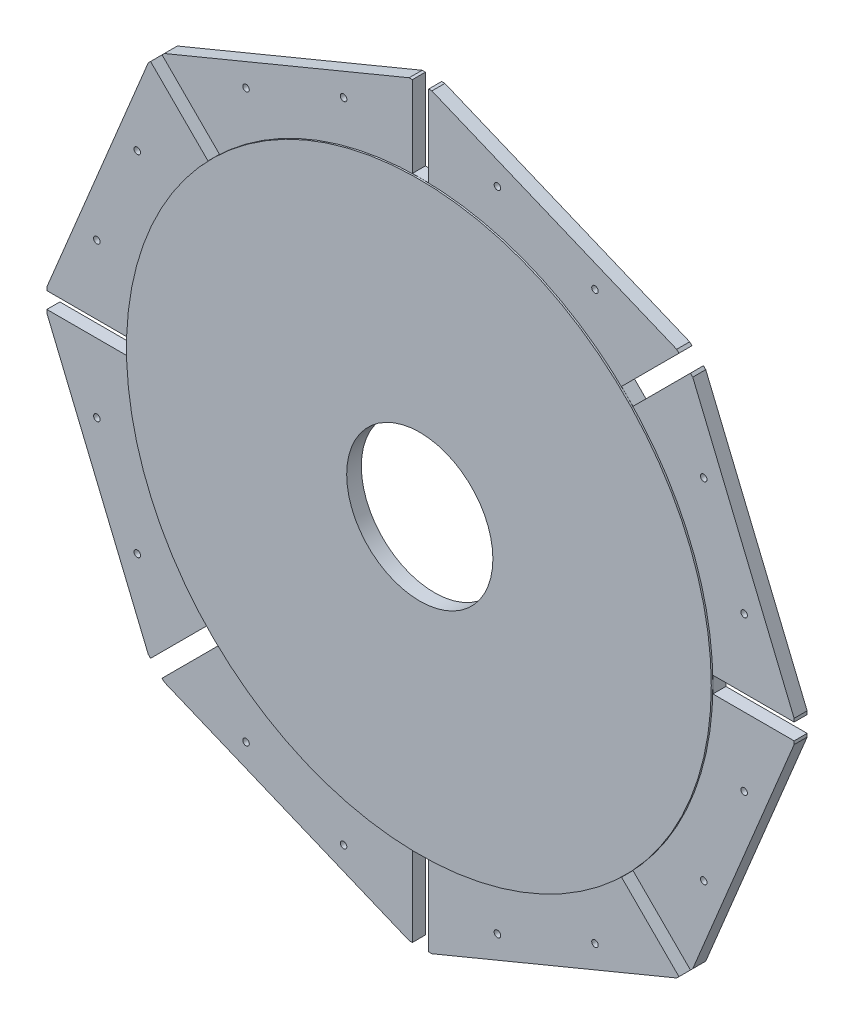
from build123d import *

# Parameters (mm, degrees)
BOSS_EXTRUDE1_DEPTH = 8
SKETCH2_R           = 180
BOSS_EXTRUDE2_DEPTH = 1
CUT_EXTRUDE1_REACH  = 10
SKETCH3_R           = 2
CUT_EXTRUDE2_REACH  = 11
SKETCH4_R           = 45


with BuildPart() as part:
    # Sketch1 → Boss-Extrude1 (new body)
    with BuildSketch(Plane.XY):
        Polygon((5, 230), (5, 180), (-5, 180), (-5, 230), (-7, 230), (-157.684812205, 167.584307141), (-159.099025767, 166.170093579), (-123.743686708, 130.814754519), (-130.81475452, 123.743686708), (-166.170093579, 159.099025767), (-167.584307141, 157.684812205), (-230, 7), (-230, 5), (-180, 5), (-180, -5), (-230, -5), (-230, -7), (-167.584307141, -157.684812205), (-166.170093579, -159.099025767), (-130.81475452, -123.743686708), (-123.743686708, -130.81475452), (-159.099025767, -166.170093579), (-157.684812205, -167.584307141), (-7, -230), (-5, -230), (-5, -180), (5, -180), (5, -230), (7, -230), (157.684812205, -167.584307141), (159.099025767, -166.170093579), (123.743686708, -130.814754519), (130.81475452, -123.743686708), (166.170093579, -159.099025767), (167.584307141, -157.684812205), (230, -7), (230, -5), (180, -5), (180, 5), (230, 5), (230, 7), (167.584307141, 157.684812205), (166.170093579, 159.099025767), (130.81475452, 123.743686708), (123.743686708, 130.81475452), (159.099025767, 166.170093579), (157.684812205, 167.584307141), (7, 230), align=None)
    extrude(amount=BOSS_EXTRUDE1_DEPTH)

    # Sketch2 → Boss-Extrude2 (add)
    with BuildSketch(Plane.XY.offset(8)):
        Circle(SKETCH2_R)
    extrude(amount=BOSS_EXTRUDE2_DEPTH)

    # Sketch3 → Cut-Extrude1 (cut, up to next)
    with BuildSketch(Plane.XY.offset(8), mode=Mode.PRIVATE) as cut_extrude1_sk1:
        with Locations((107.397750993, 174.354514299)):
            Circle(SKETCH3_R)
    cut_extrude1_tool1 = extrude(cut_extrude1_sk1.sketch, amount=-CUT_EXTRUDE1_REACH, mode=Mode.PRIVATE) & part.part
    add(cut_extrude1_tool1.solids().sort_by_distance((107.397751, 174.354514, 8))[0], mode=Mode.SUBTRACT)
    # Sketch3 → Cut-Extrude1 (cut, up to next)
    with BuildSketch(Plane.XY.offset(8), mode=Mode.PRIVATE) as cut_extrude1_sk2:
        with Locations((47.34558138, 199.228937402)):
            Circle(SKETCH3_R)
    cut_extrude1_tool2 = extrude(cut_extrude1_sk2.sketch, amount=-CUT_EXTRUDE1_REACH, mode=Mode.PRIVATE) & part.part
    add(cut_extrude1_tool2.solids().sort_by_distance((47.345581, 199.228937, 8))[0], mode=Mode.SUBTRACT)
    # Sketch3 → Cut-Extrude1 (cut, up to next)
    with BuildSketch(Plane.XY.offset(8), mode=Mode.PRIVATE) as cut_extrude1_sk3:
        with Locations((199.228937402, 47.34558138)):
            Circle(SKETCH3_R)
    cut_extrude1_tool3 = extrude(cut_extrude1_sk3.sketch, amount=-CUT_EXTRUDE1_REACH, mode=Mode.PRIVATE) & part.part
    add(cut_extrude1_tool3.solids().sort_by_distance((199.228937, 47.345581, 8))[0], mode=Mode.SUBTRACT)
    # Sketch3 → Cut-Extrude1 (cut, up to next)
    with BuildSketch(Plane.XY.offset(8), mode=Mode.PRIVATE) as cut_extrude1_sk4:
        with Locations((174.354514299, 107.397750993)):
            Circle(SKETCH3_R)
    cut_extrude1_tool4 = extrude(cut_extrude1_sk4.sketch, amount=-CUT_EXTRUDE1_REACH, mode=Mode.PRIVATE) & part.part
    add(cut_extrude1_tool4.solids().sort_by_distance((174.354514, 107.397751, 8))[0], mode=Mode.SUBTRACT)
    # Sketch3 → Cut-Extrude1 (cut, up to next)
    with BuildSketch(Plane.XY.offset(8), mode=Mode.PRIVATE) as cut_extrude1_sk5:
        with Locations((174.354514299, -107.397750993)):
            Circle(SKETCH3_R)
    cut_extrude1_tool5 = extrude(cut_extrude1_sk5.sketch, amount=-CUT_EXTRUDE1_REACH, mode=Mode.PRIVATE) & part.part
    add(cut_extrude1_tool5.solids().sort_by_distance((174.354514, -107.397751, 8))[0], mode=Mode.SUBTRACT)
    # Sketch3 → Cut-Extrude1 (cut, up to next)
    with BuildSketch(Plane.XY.offset(8), mode=Mode.PRIVATE) as cut_extrude1_sk6:
        with Locations((199.228937402, -47.34558138)):
            Circle(SKETCH3_R)
    cut_extrude1_tool6 = extrude(cut_extrude1_sk6.sketch, amount=-CUT_EXTRUDE1_REACH, mode=Mode.PRIVATE) & part.part
    add(cut_extrude1_tool6.solids().sort_by_distance((199.228937, -47.345581, 8))[0], mode=Mode.SUBTRACT)
    # Sketch3 → Cut-Extrude1 (cut, up to next)
    with BuildSketch(Plane.XY.offset(8), mode=Mode.PRIVATE) as cut_extrude1_sk7:
        with Locations((47.34558138, -199.228937402)):
            Circle(SKETCH3_R)
    cut_extrude1_tool7 = extrude(cut_extrude1_sk7.sketch, amount=-CUT_EXTRUDE1_REACH, mode=Mode.PRIVATE) & part.part
    add(cut_extrude1_tool7.solids().sort_by_distance((47.345581, -199.228937, 8))[0], mode=Mode.SUBTRACT)
    # Sketch3 → Cut-Extrude1 (cut, up to next)
    with BuildSketch(Plane.XY.offset(8), mode=Mode.PRIVATE) as cut_extrude1_sk8:
        with Locations((107.397750993, -174.354514299)):
            Circle(SKETCH3_R)
    cut_extrude1_tool8 = extrude(cut_extrude1_sk8.sketch, amount=-CUT_EXTRUDE1_REACH, mode=Mode.PRIVATE) & part.part
    add(cut_extrude1_tool8.solids().sort_by_distance((107.397751, -174.354514, 8))[0], mode=Mode.SUBTRACT)
    # Sketch3 → Cut-Extrude1 (cut, up to next)
    with BuildSketch(Plane.XY.offset(8), mode=Mode.PRIVATE) as cut_extrude1_sk9:
        with Locations((-107.397750993, -174.354514299)):
            Circle(SKETCH3_R)
    cut_extrude1_tool9 = extrude(cut_extrude1_sk9.sketch, amount=-CUT_EXTRUDE1_REACH, mode=Mode.PRIVATE) & part.part
    add(cut_extrude1_tool9.solids().sort_by_distance((-107.397751, -174.354514, 8))[0], mode=Mode.SUBTRACT)
    # Sketch3 → Cut-Extrude1 (cut, up to next)
    with BuildSketch(Plane.XY.offset(8), mode=Mode.PRIVATE) as cut_extrude1_sk10:
        with Locations((-47.34558138, -199.228937402)):
            Circle(SKETCH3_R)
    cut_extrude1_tool10 = extrude(cut_extrude1_sk10.sketch, amount=-CUT_EXTRUDE1_REACH, mode=Mode.PRIVATE) & part.part
    add(cut_extrude1_tool10.solids().sort_by_distance((-47.345581, -199.228937, 8))[0], mode=Mode.SUBTRACT)
    # Sketch3 → Cut-Extrude1 (cut, up to next)
    with BuildSketch(Plane.XY.offset(8), mode=Mode.PRIVATE) as cut_extrude1_sk11:
        with Locations((-199.228937402, -47.34558138)):
            Circle(SKETCH3_R)
    cut_extrude1_tool11 = extrude(cut_extrude1_sk11.sketch, amount=-CUT_EXTRUDE1_REACH, mode=Mode.PRIVATE) & part.part
    add(cut_extrude1_tool11.solids().sort_by_distance((-199.228937, -47.345581, 8))[0], mode=Mode.SUBTRACT)
    # Sketch3 → Cut-Extrude1 (cut, up to next)
    with BuildSketch(Plane.XY.offset(8), mode=Mode.PRIVATE) as cut_extrude1_sk12:
        with Locations((-174.354514299, -107.397750993)):
            Circle(SKETCH3_R)
    cut_extrude1_tool12 = extrude(cut_extrude1_sk12.sketch, amount=-CUT_EXTRUDE1_REACH, mode=Mode.PRIVATE) & part.part
    add(cut_extrude1_tool12.solids().sort_by_distance((-174.354514, -107.397751, 8))[0], mode=Mode.SUBTRACT)
    # Sketch3 → Cut-Extrude1 (cut, up to next)
    with BuildSketch(Plane.XY.offset(8), mode=Mode.PRIVATE) as cut_extrude1_sk13:
        with Locations((-174.354514299, 107.397750993)):
            Circle(SKETCH3_R)
    cut_extrude1_tool13 = extrude(cut_extrude1_sk13.sketch, amount=-CUT_EXTRUDE1_REACH, mode=Mode.PRIVATE) & part.part
    add(cut_extrude1_tool13.solids().sort_by_distance((-174.354514, 107.397751, 8))[0], mode=Mode.SUBTRACT)
    # Sketch3 → Cut-Extrude1 (cut, up to next)
    with BuildSketch(Plane.XY.offset(8), mode=Mode.PRIVATE) as cut_extrude1_sk14:
        with Locations((-199.228937402, 47.34558138)):
            Circle(SKETCH3_R)
    cut_extrude1_tool14 = extrude(cut_extrude1_sk14.sketch, amount=-CUT_EXTRUDE1_REACH, mode=Mode.PRIVATE) & part.part
    add(cut_extrude1_tool14.solids().sort_by_distance((-199.228937, 47.345581, 8))[0], mode=Mode.SUBTRACT)
    # Sketch3 → Cut-Extrude1 (cut, up to next)
    with BuildSketch(Plane.XY.offset(8), mode=Mode.PRIVATE) as cut_extrude1_sk15:
        with Locations((-47.34558138, 199.228937402)):
            Circle(SKETCH3_R)
    cut_extrude1_tool15 = extrude(cut_extrude1_sk15.sketch, amount=-CUT_EXTRUDE1_REACH, mode=Mode.PRIVATE) & part.part
    add(cut_extrude1_tool15.solids().sort_by_distance((-47.345581, 199.228937, 8))[0], mode=Mode.SUBTRACT)
    # Sketch3 → Cut-Extrude1 (cut, up to next)
    with BuildSketch(Plane.XY.offset(8), mode=Mode.PRIVATE) as cut_extrude1_sk16:
        with Locations((-107.397750993, 174.354514299)):
            Circle(SKETCH3_R)
    cut_extrude1_tool16 = extrude(cut_extrude1_sk16.sketch, amount=-CUT_EXTRUDE1_REACH, mode=Mode.PRIVATE) & part.part
    add(cut_extrude1_tool16.solids().sort_by_distance((-107.397751, 174.354514, 8))[0], mode=Mode.SUBTRACT)

    # Sketch4 → Cut-Extrude2 (cut, up to next)
    with BuildSketch(Plane(origin=(0, 0, 0), x_dir=(-1, 0, 0), z_dir=(0, 0, -1)), mode=Mode.PRIVATE) as cut_extrude2_sk1:
        with Locations((-0.557942617, 0.278971308)):
            Circle(SKETCH4_R)
    cut_extrude2_tool1 = extrude(cut_extrude2_sk1.sketch, amount=-CUT_EXTRUDE2_REACH, mode=Mode.PRIVATE) & part.part
    add(cut_extrude2_tool1.solids().sort_by_distance((0.557943, 0.278971, 0))[0], mode=Mode.SUBTRACT)


solid = part.part
